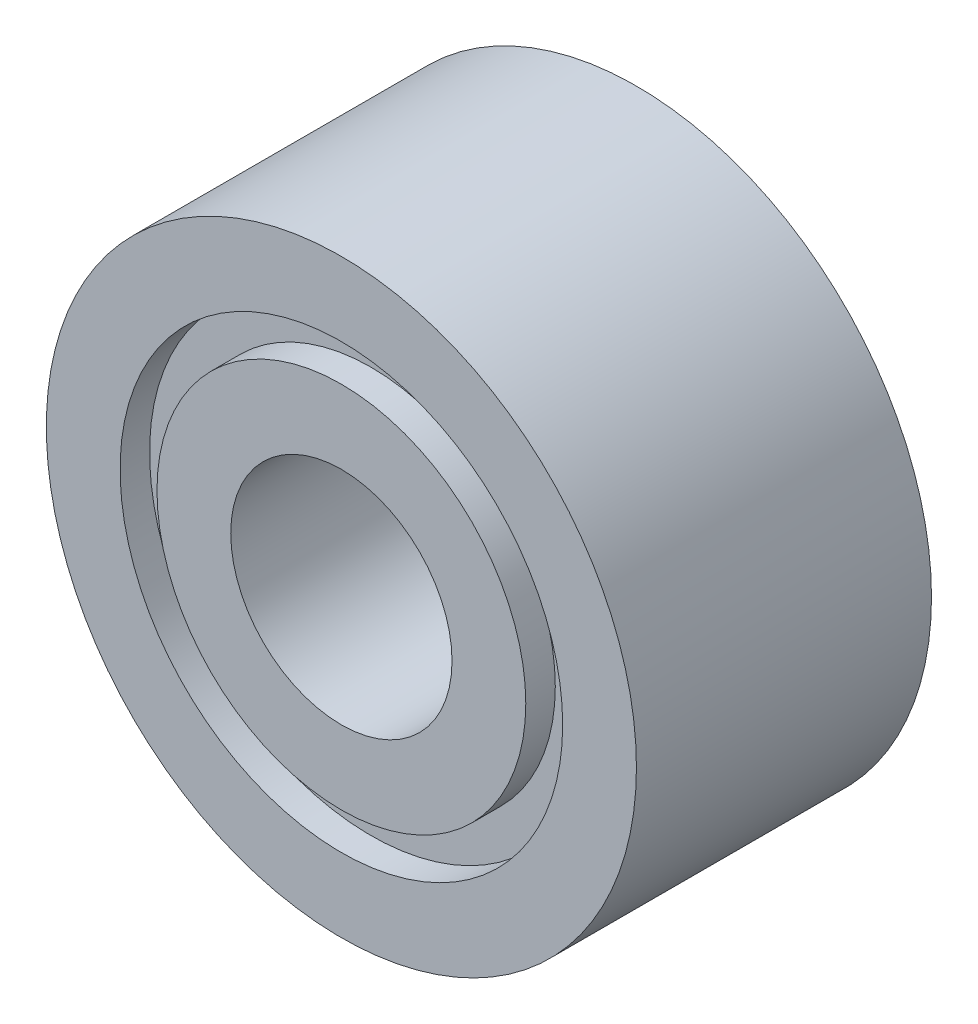
from build123d import *


with BuildPart() as part:
    # Sketch2 → Revolve1 (revolve)
    with BuildSketch(Plane(origin=(0, 0, 0), x_dir=(0, 0, -1), z_dir=(1, 0, 0))):
        Polygon((1.10919003, 2), (3.10919003, 2), (3.10919003, 1.5), (2.90919003, 1.5), (2.90919003, 1.25), (3.10919003, 1.25), (3.10919003, 0.75), (1.10919003, 0.75), (1.10919003, 1.25), (1.30919003, 1.25), (1.30919003, 1.5), (1.10919003, 1.5), align=None)
    revolve(axis=Axis((0, 0, 0), (0, 0, -1)))


solid = part.part
